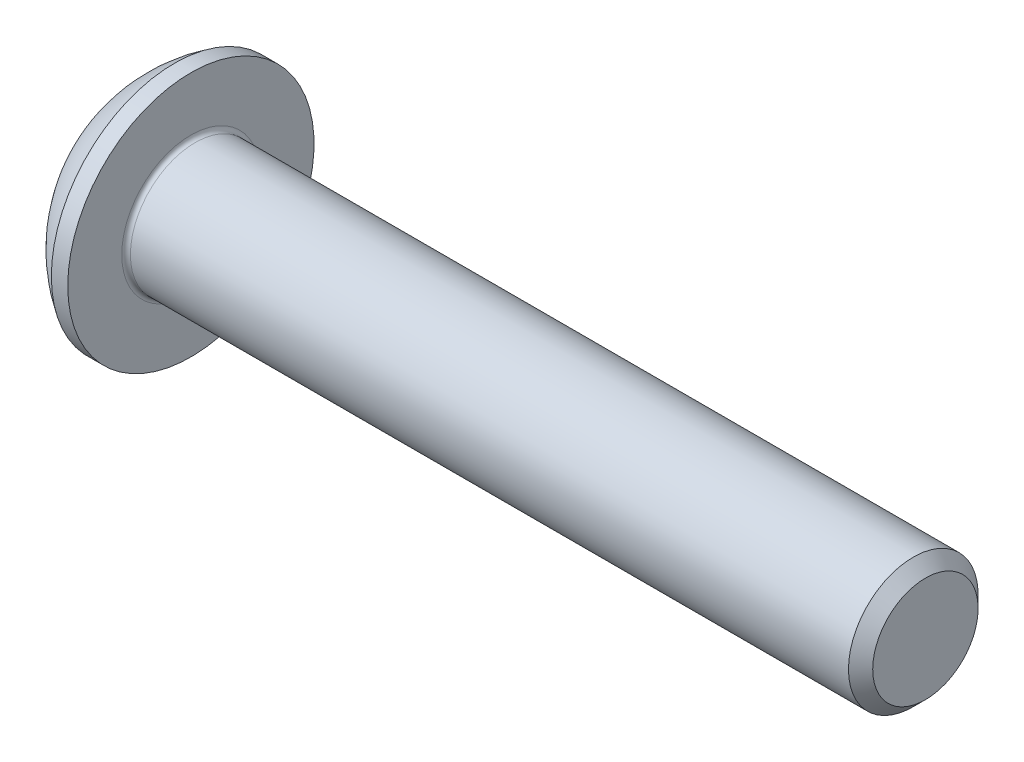
from build123d import *

# Parameters (mm, degrees)
FILLET1_R   = 0.1
HEX_2_DEPTH = 1.04


with BuildPart() as part:
    # BodySke → BaseBody (revolve)
    with BuildSketch(Plane.XY, mode=Mode.PRIVATE) as basebody_sk:
        with BuildLine():
            Line((18.65, 0), (18.65, 1.2195))
            Line((18.65, 1.2195), (18.3695, 1.5))
            Line((18.3695, 1.5), (1.65, 1.5))
            Line((1.65, 1.5), (1.65, 2.85))
            Line((1.65, 2.85), (1.27, 2.85))
            ThreePointArc((1.27, 2.85), (0.53140404, 2.229827628), (0, 1.425))
            Line((0, 1.425), (0, 0))
            Line((0, 0), (18.65, 0))
        make_face()
    revolve(basebody_sk.sketch.rotate(Axis((0, 0, 0), (1, 0, 0)), 90), axis=Axis((0, 0, 0), (1, 0, 0)))  # turned: the seam where the file's is

    # Fillet1
    fillet1_edges = [part.edges().sort_by_distance(p)[0] for p in [
        (1.65, 0, -1.5),
    ]]
    fillet(fillet1_edges, radius=FILLET1_R)

    # Sketch2 → PreBroach (revolve, cut)
    with BuildSketch(Plane.XY, mode=Mode.PRIVATE) as prebroach_sk:
        Polygon((0, 1), (1.04, 1), (1.617350269, 0), (0, 0), align=None)
    revolve(prebroach_sk.sketch.rotate(Axis((0, 0, 0), (1, 0, 0)), 90), axis=Axis((0, 0, 0), (1, 0, 0)), mode=Mode.SUBTRACT)  # turned: the seam where the file's is

    # Sketch3 → Hex 2 (cut)
    with BuildSketch(Plane(origin=(0, 0, 0), x_dir=(0, 0, -1), z_dir=(1, 0, 0))):
        Polygon((-1, -0.577350269), (-1, 0.577350269), (0, 1.154700538), (1, 0.577350269), (1, -0.577350269), (0, -1.154700538), align=None)
    extrude(amount=HEX_2_DEPTH, mode=Mode.SUBTRACT)


solid = part.part
